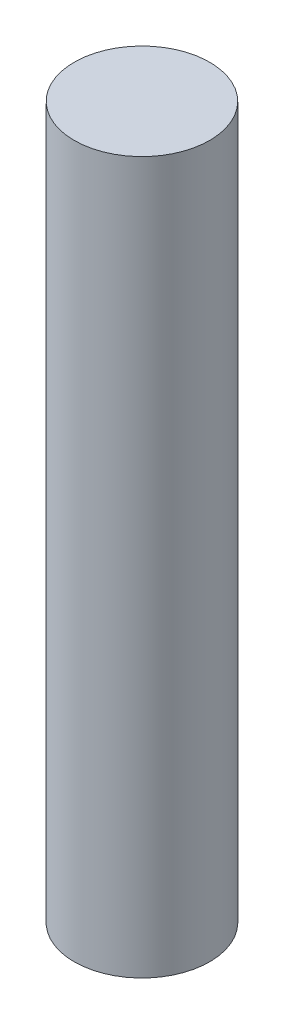
from build123d import *

# Parameters (mm, degrees)
SKETCH1_R           = 2
BOSS_EXTRUDE1_DEPTH = 21


with BuildPart() as part:
    # Sketch1 → Boss-Extrude1 (new body)
    with BuildSketch(Plane(origin=(0, 0, 0), x_dir=(1, 0, 0), z_dir=(0, 1, 0))):
        Circle(SKETCH1_R)
    extrude(amount=BOSS_EXTRUDE1_DEPTH)


solid = part.part
